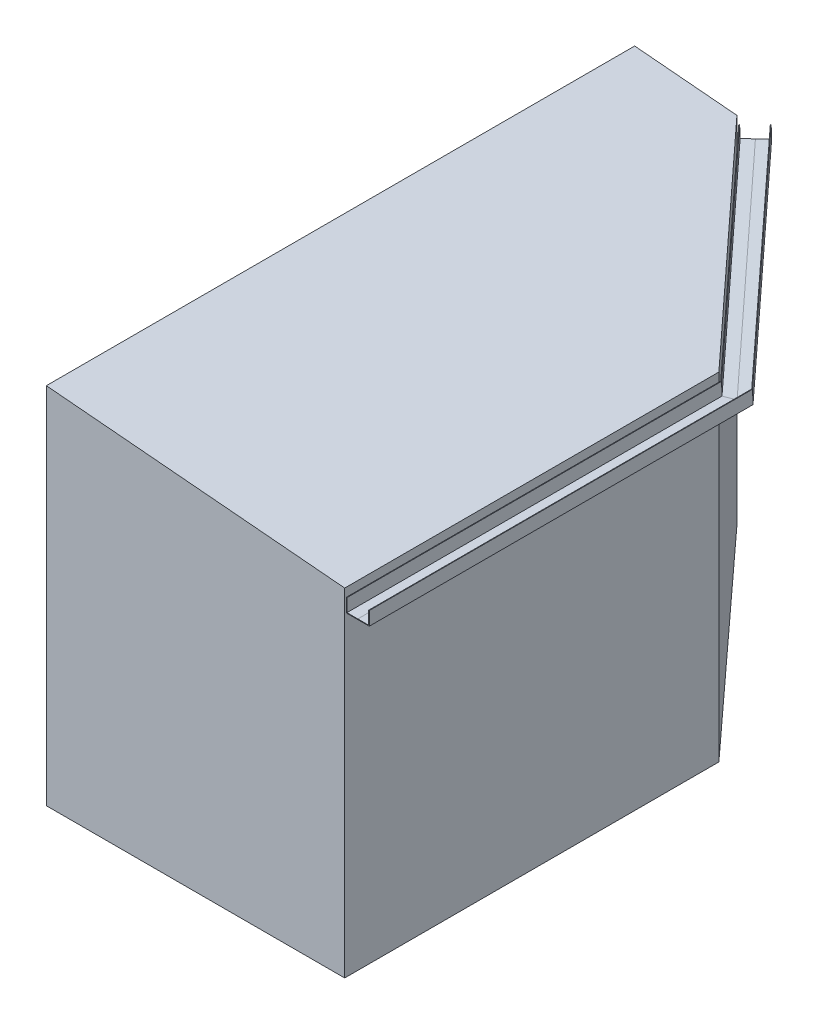
from build123d import *

# Parameters (mm, degrees)
AUFSATZ_LINEAR_AUSTRAGEN1_DEPTH = 3048.54
SCHNITT_LINEAR_AUSTRAGEN1_DEPTH = 4931


with BuildPart() as part:
    # Skizze1 → Aufsatz-Linear austragen1 (new body)
    with BuildSketch(Plane(origin=(0, 0, 0), x_dir=(1, 0, 0), z_dir=(0, 1, 0))):
        Polygon((-2500, 4930), (-2500, 0), (0, 0), (0, 3135.547559896), (-1643.224828015, 4930), align=None)
    extrude(amount=AUFSATZ_LINEAR_AUSTRAGEN1_DEPTH)

    # Skizze2 → Schnitt-Linear austragen1 (cut, through all)
    with BuildSketch(Plane.XY):
        Polygon((-2500, 3048.54), (0, 2829.818341185), (0, 3048.54), align=None)
    extrude(amount=-SCHNITT_LINEAR_AUSTRAGEN1_DEPTH, mode=Mode.SUBTRACT)


with BuildPart() as body_2:
    # Austragung3: sweep along a path in Skizze4
    with BuildLine(Plane(origin=(230.711125671, 2637.040233244, 0), x_dir=(0.996194698, -0.087155743, 0), z_dir=(0.087155743, 0.996194698, 0))) as austragung3_path:
        Line((-231.59240469, 0), (-231.59240469, 3135.547559896))
        Line((-231.59240469, 3135.547559896), (-1881.094084596, 4930))
    # Skizze3 → Austragung3 (sweep)
    with BuildSketch(Plane.XY):
        Polygon((14, 2656), (14, 2770), (19, 2770), (19, 2661), (110, 2661), (201, 2661), (201, 2770), (206, 2770), (206, 2656), (110, 2656), align=None)
    sweep(path=austragung3_path.line, transition=Transition.RIGHT)


solid = Compound([part.part, body_2.part])
